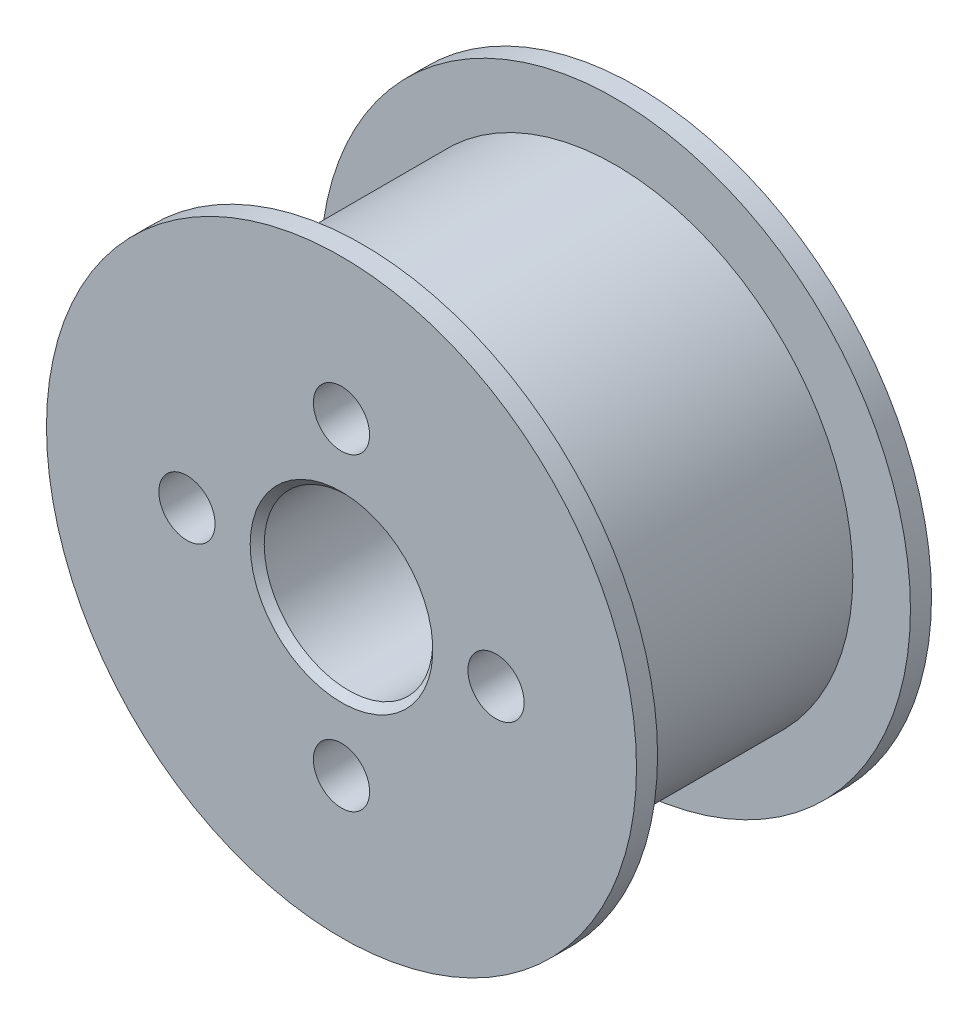
from build123d import *

# Parameters (mm, degrees)
SKETCH2_R                                           = 6
CUT_EXTRUDE1_DEPTH                                  = 40.471508712
CBORE_FOR_M4_HEX_SOCKET_HEAD_CAP_SCREW1_D           = 4
CBORE_FOR_M4_HEX_SOCKET_HEAD_CAP_SCREW1_CBORE_D     = 8
CBORE_FOR_M4_HEX_SOCKET_HEAD_CAP_SCREW1_CBORE_DEPTH = 5
CHAMFER1_SIZE                                       = 0.5


with BuildPart() as part:
    # Sketch1 → Revolve1 (revolve)
    with BuildSketch(Plane(origin=(0, 0, 0), x_dir=(0, 0, -1), z_dir=(1, 0, 0))):
        Polygon((0, 0), (26, 0), (26, 13), (21, 13), (21, 21), (19.5, 21), (19.5, 16.9), (1.5, 16.9), (1.5, 21), (0, 21), align=None)
    revolve(axis=Axis((0, 0, 0), (0, 0, -1)))

    # Sketch2 → Cut-Extrude1 (cut, through all)
    with BuildSketch(Plane(origin=(0, 0, -26), x_dir=(-1, 0, 0), z_dir=(0, 0, -1))):
        Circle(SKETCH2_R)
    extrude(amount=-CUT_EXTRUDE1_DEPTH, mode=Mode.SUBTRACT)

    # CBORE for M4 Hex Socket Head Cap Screw1 (through all)
    with Locations(Plane(origin=(0, 0, -26), x_dir=(-1, 0, 0), z_dir=(0, 0, -1))):
        with Locations((0, 11), (11, 0), (0, -11), (-11, 0)):
            CounterBoreHole(CBORE_FOR_M4_HEX_SOCKET_HEAD_CAP_SCREW1_D / 2, CBORE_FOR_M4_HEX_SOCKET_HEAD_CAP_SCREW1_CBORE_D / 2, CBORE_FOR_M4_HEX_SOCKET_HEAD_CAP_SCREW1_CBORE_DEPTH)

    # Chamfer1
    chamfer1_edges = [part.edges().sort_by_distance(p)[0] for p in [
        (6, 0, 0),
    ]]
    chamfer(chamfer1_edges, length=CHAMFER1_SIZE)


solid = part.part
